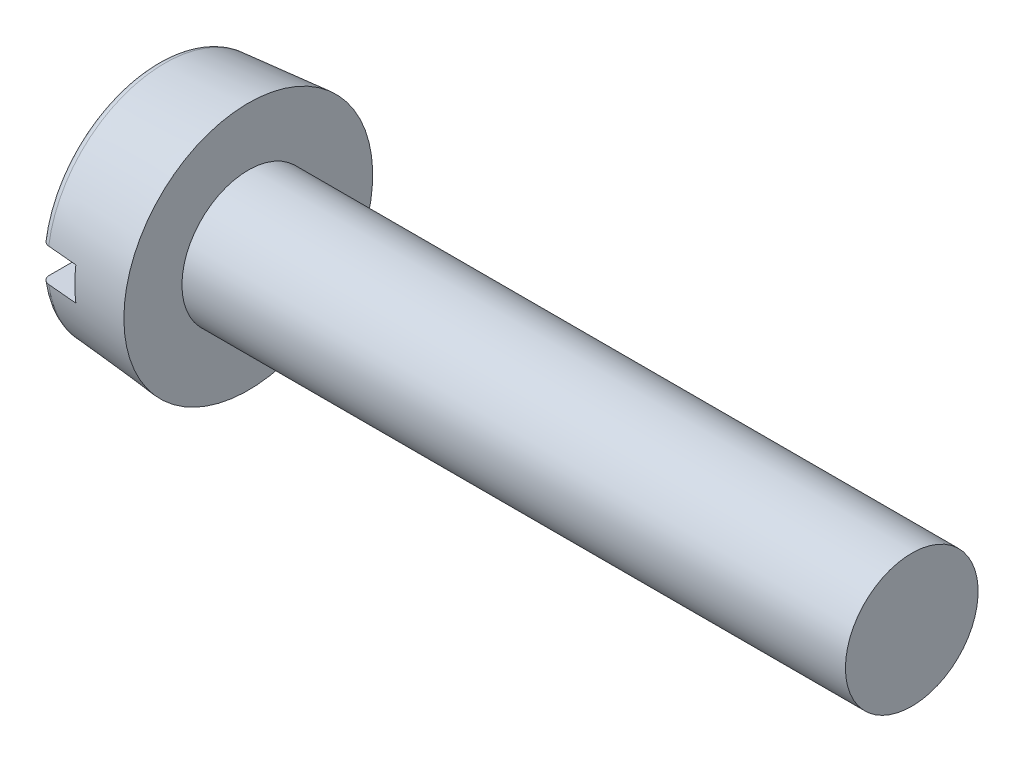
from build123d import *

# Parameters (mm, degrees)
FILLET2_R  = 0.1
SKETCH2_W  = 3
SKETCH2_H  = 0.4
SLOT_DEPTH = 0.45


with BuildPart() as part:
    # BodySke → Base-Revolve (revolve)
    with BuildSketch(Plane.XY):
        Polygon((1.1, 0.8), (1.1, 1.5), (0, 1.40376247), (0, 0), (9.1, 0), (9.1, 0.8), align=None)
    revolve(axis=Axis((-25.4, 0, 0), (1, 0, 0)))

    # Fillet2
    fillet2_edges = [part.edges().sort_by_distance(p)[0] for p in [
        (0, -1.40376247, 0),
    ]]
    fillet(fillet2_edges, radius=FILLET2_R)

    # Sketch2 → Slot (cut)
    with BuildSketch(Plane(origin=(0, 0, 0), x_dir=(0, 0, -1), z_dir=(1, 0, 0))):
        Rectangle(SKETCH2_W, SKETCH2_H)
    extrude(amount=SLOT_DEPTH, mode=Mode.SUBTRACT)


solid = part.part
